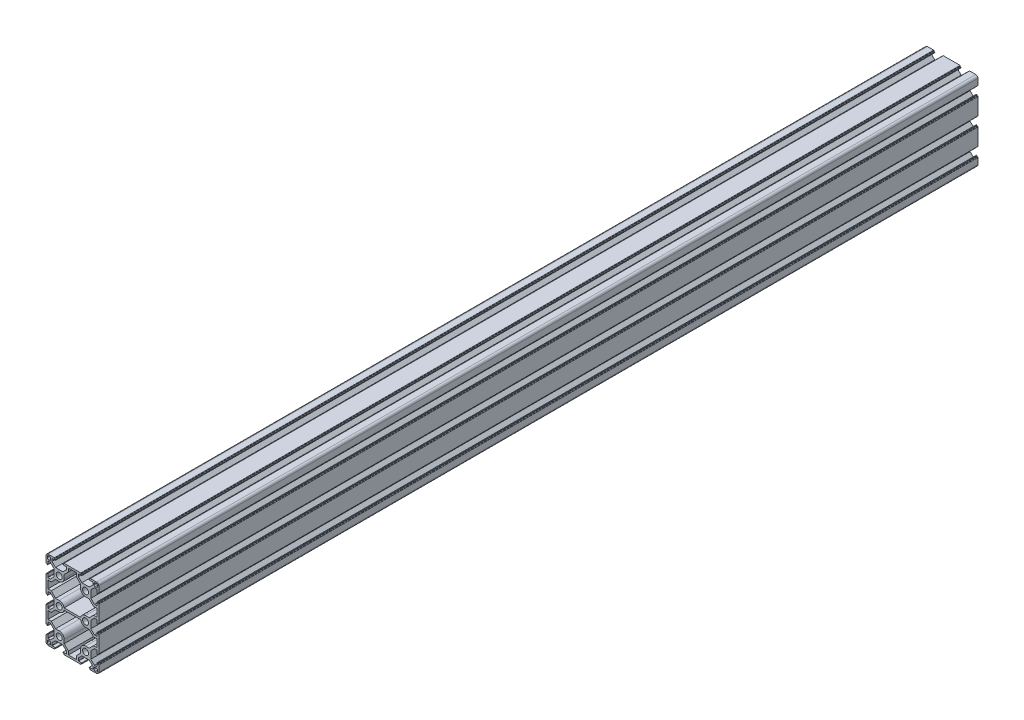
from build123d import *

# Parameters (mm, degrees)
SKETCH_1_R      = 3.4
EXTRUDE_1_DEPTH = 1000


with BuildPart() as part:
    # Эскиз1 → Бобышка-Вытянуть1 (new body)
    with BuildSketch(Plane.XY):
        with BuildLine():
            Line((-30, 38.25), (-30, 42.5))
            ThreePointArc((-30, 42.5), (-29.267766953, 44.267766953), (-27.5, 45))
            Line((-27.5, 45), (-23.25, 45))
            Line((-23.25, 45), (-20.5, 45))
            ThreePointArc((-20.5, 45), (-20.287867966, 44.912132034), (-20.2, 44.7))
            Line((-20.2, 44.7), (-20.2, 44.3))
            ThreePointArc((-20.2, 44.3), (-20.112132034, 44.087867966), (-19.9, 44))
            Line((-19.9, 44), (-19.4, 44))
            ThreePointArc((-19.4, 44), (-19.187867966, 43.912132034), (-19.1, 43.7))
            Line((-19.1, 43.7), (-19.1, 43.3))
            ThreePointArc((-19.1, 43.3), (-19.187867966, 43.087867966), (-19.4, 43))
            Line((-19.4, 43), (-22.95, 43))
            ThreePointArc((-22.95, 43), (-23.162132034, 42.912132034), (-23.25, 42.7))
            Line((-23.25, 42.7), (-23.25, 40.05))
            Line((-23.25, 40.05), (-19.2, 36))
            Line((-19.2, 36), (-10.8, 36))
            Line((-10.8, 36), (-6.75, 40.05))
            Line((-6.75, 40.05), (-6.75, 42.7))
            ThreePointArc((-6.75, 42.7), (-6.837867966, 42.912132034), (-7.05, 43))
            Line((-7.05, 43), (-10.6, 43))
            ThreePointArc((-10.6, 43), (-10.812132034, 43.087867966), (-10.9, 43.3))
            Line((-10.9, 43.3), (-10.9, 43.7))
            ThreePointArc((-10.9, 43.7), (-10.812132034, 43.912132034), (-10.6, 44))
            Line((-10.6, 44), (-10.1, 44))
            ThreePointArc((-10.1, 44), (-9.887867966, 44.087867966), (-9.8, 44.3))
            Line((-9.8, 44.3), (-9.8, 44.7))
            ThreePointArc((-9.8, 44.7), (-9.712132034, 44.912132034), (-9.5, 45))
            Line((-9.5, 45), (-6.75, 45))
            Line((-6.75, 45), (6.75, 45))
            Line((6.75, 45), (9.5, 45))
            ThreePointArc((9.5, 45), (9.712132034, 44.912132034), (9.8, 44.7))
            Line((9.8, 44.7), (9.8, 44.3))
            ThreePointArc((9.8, 44.3), (9.887867966, 44.087867966), (10.1, 44))
            Line((10.1, 44), (10.6, 44))
            ThreePointArc((10.6, 44), (10.812132034, 43.912132034), (10.9, 43.7))
            Line((10.9, 43.7), (10.9, 43.3))
            ThreePointArc((10.9, 43.3), (10.812132034, 43.087867966), (10.6, 43))
            Line((10.6, 43), (7.05, 43))
            ThreePointArc((7.05, 43), (6.837867966, 42.912132034), (6.75, 42.7))
            Line((6.75, 42.7), (6.75, 40.05))
            Line((6.75, 40.05), (10.8, 36))
            Line((10.8, 36), (19.2, 36))
            Line((19.2, 36), (23.25, 40.05))
            Line((23.25, 40.05), (23.25, 42.7))
            ThreePointArc((23.25, 42.7), (23.162132034, 42.912132034), (22.95, 43))
            Line((22.95, 43), (19.4, 43))
            ThreePointArc((19.4, 43), (19.187867966, 43.087867966), (19.1, 43.3))
            Line((19.1, 43.3), (19.1, 43.7))
            ThreePointArc((19.1, 43.7), (19.187867966, 43.912132034), (19.4, 44))
            Line((19.4, 44), (19.9, 44))
            ThreePointArc((19.9, 44), (20.112132034, 44.087867966), (20.2, 44.3))
            Line((20.2, 44.3), (20.2, 44.7))
            ThreePointArc((20.2, 44.7), (20.287867966, 44.912132034), (20.5, 45))
            Line((20.5, 45), (23.25, 45))
            Line((23.25, 45), (27.5, 45))
            ThreePointArc((27.5, 45), (29.267766953, 44.267766953), (30, 42.5))
            Line((30, 42.5), (30, 38.25))
            Line((30, 38.25), (30, 35.5))
            ThreePointArc((30, 35.5), (29.912132034, 35.287867966), (29.7, 35.2))
            Line((29.7, 35.2), (29.3, 35.2))
            ThreePointArc((29.3, 35.2), (29.087867966, 35.112132034), (29, 34.9))
            Line((29, 34.9), (29, 34.4))
            ThreePointArc((29, 34.4), (28.912132034, 34.187867966), (28.7, 34.1))
            Line((28.7, 34.1), (28.3, 34.1))
            ThreePointArc((28.3, 34.1), (28.087867966, 34.187867966), (28, 34.4))
            Line((28, 34.4), (28, 37.95))
            ThreePointArc((28, 37.95), (27.912132034, 38.162132034), (27.7, 38.25))
            Line((27.7, 38.25), (25.05, 38.25))
            Line((25.05, 38.25), (21, 34.2))
            Line((21, 34.2), (21, 25.8))
            Line((21, 25.8), (25.05, 21.75))
            Line((25.05, 21.75), (27.7, 21.75))
            ThreePointArc((27.7, 21.75), (27.912132034, 21.837867966), (28, 22.05))
            Line((28, 22.05), (28, 25.6))
            ThreePointArc((28, 25.6), (28.087867966, 25.812132034), (28.3, 25.9))
            Line((28.3, 25.9), (28.7, 25.9))
            ThreePointArc((28.7, 25.9), (28.912132034, 25.812132034), (29, 25.6))
            Line((29, 25.6), (29, 25.1))
            ThreePointArc((29, 25.1), (29.087867966, 24.887867966), (29.3, 24.8))
            Line((29.3, 24.8), (29.7, 24.8))
            ThreePointArc((29.7, 24.8), (29.912132034, 24.712132034), (30, 24.5))
            Line((30, 24.5), (30, 21.75))
            Line((30, 21.75), (30, 8.25))
            Line((30, 8.25), (30, 5.5))
            ThreePointArc((30, 5.5), (29.912132034, 5.287867966), (29.7, 5.2))
            Line((29.7, 5.2), (29.3, 5.2))
            ThreePointArc((29.3, 5.2), (29.087867966, 5.112132034), (29, 4.9))
            Line((29, 4.9), (29, 4.4))
            ThreePointArc((29, 4.4), (28.912132034, 4.187867966), (28.7, 4.1))
            Line((28.7, 4.1), (28.3, 4.1))
            ThreePointArc((28.3, 4.1), (28.087867966, 4.187867966), (28, 4.4))
            Line((28, 4.4), (28, 7.95))
            ThreePointArc((28, 7.95), (27.912132034, 8.162132034), (27.7, 8.25))
            Line((27.7, 8.25), (25.05, 8.25))
            Line((25.05, 8.25), (21, 4.2))
            Line((21, 4.2), (21, -4.2))
            Line((21, -4.2), (25.05, -8.25))
            Line((25.05, -8.25), (27.7, -8.25))
            ThreePointArc((27.7, -8.25), (27.912132034, -8.162132034), (28, -7.95))
            Line((28, -7.95), (28, -4.4))
            ThreePointArc((28, -4.4), (28.087867966, -4.187867966), (28.3, -4.1))
            Line((28.3, -4.1), (28.7, -4.1))
            ThreePointArc((28.7, -4.1), (28.912132034, -4.187867966), (29, -4.4))
            Line((29, -4.4), (29, -4.9))
            ThreePointArc((29, -4.9), (29.087867966, -5.112132034), (29.3, -5.2))
            Line((29.3, -5.2), (29.7, -5.2))
            ThreePointArc((29.7, -5.2), (29.912132034, -5.287867966), (30, -5.5))
            Line((30, -5.5), (30, -8.25))
            Line((30, -8.25), (30, -21.75))
            Line((30, -21.75), (30, -24.5))
            ThreePointArc((30, -24.5), (29.912132034, -24.712132034), (29.7, -24.8))
            Line((29.7, -24.8), (29.3, -24.8))
            ThreePointArc((29.3, -24.8), (29.087867966, -24.887867966), (29, -25.1))
            Line((29, -25.1), (29, -25.6))
            ThreePointArc((29, -25.6), (28.912132034, -25.812132034), (28.7, -25.9))
            Line((28.7, -25.9), (28.3, -25.9))
            ThreePointArc((28.3, -25.9), (28.087867966, -25.812132034), (28, -25.6))
            Line((28, -25.6), (28, -22.05))
            ThreePointArc((28, -22.05), (27.912132034, -21.837867966), (27.7, -21.75))
            Line((27.7, -21.75), (25.05, -21.75))
            Line((25.05, -21.75), (21, -25.8))
            Line((21, -25.8), (21, -34.2))
            Line((21, -34.2), (25.05, -38.25))
            Line((25.05, -38.25), (27.7, -38.25))
            ThreePointArc((27.7, -38.25), (27.912132034, -38.162132034), (28, -37.95))
            Line((28, -37.95), (28, -34.4))
            ThreePointArc((28, -34.4), (28.087867966, -34.187867966), (28.3, -34.1))
            Line((28.3, -34.1), (28.7, -34.1))
            ThreePointArc((28.7, -34.1), (28.912132034, -34.187867966), (29, -34.4))
            Line((29, -34.4), (29, -34.9))
            ThreePointArc((29, -34.9), (29.087867966, -35.112132034), (29.3, -35.2))
            Line((29.3, -35.2), (29.7, -35.2))
            ThreePointArc((29.7, -35.2), (29.912132034, -35.287867966), (30, -35.5))
            Line((30, -35.5), (30, -38.25))
            Line((30, -38.25), (30, -42.5))
            ThreePointArc((30, -42.5), (29.267766953, -44.267766953), (27.5, -45))
            Line((27.5, -45), (23.25, -45))
            Line((23.25, -45), (20.5, -45))
            ThreePointArc((20.5, -45), (20.287867966, -44.912132034), (20.2, -44.7))
            Line((20.2, -44.7), (20.2, -44.3))
            ThreePointArc((20.2, -44.3), (20.112132034, -44.087867966), (19.9, -44))
            Line((19.9, -44), (19.4, -44))
            ThreePointArc((19.4, -44), (19.187867966, -43.912132034), (19.1, -43.7))
            Line((19.1, -43.7), (19.1, -43.3))
            ThreePointArc((19.1, -43.3), (19.187867966, -43.087867966), (19.4, -43))
            Line((19.4, -43), (22.95, -43))
            ThreePointArc((22.95, -43), (23.162132034, -42.912132034), (23.25, -42.7))
            Line((23.25, -42.7), (23.25, -40.05))
            Line((23.25, -40.05), (19.2, -36))
            Line((19.2, -36), (10.8, -36))
            Line((10.8, -36), (6.75, -40.05))
            Line((6.75, -40.05), (6.75, -42.7))
            ThreePointArc((6.75, -42.7), (6.837867966, -42.912132034), (7.05, -43))
            Line((7.05, -43), (10.6, -43))
            ThreePointArc((10.6, -43), (10.812132034, -43.087867966), (10.9, -43.3))
            Line((10.9, -43.3), (10.9, -43.7))
            ThreePointArc((10.9, -43.7), (10.812132034, -43.912132034), (10.6, -44))
            Line((10.6, -44), (10.1, -44))
            ThreePointArc((10.1, -44), (9.887867966, -44.087867966), (9.8, -44.3))
            Line((9.8, -44.3), (9.8, -44.7))
            ThreePointArc((9.8, -44.7), (9.712132034, -44.912132034), (9.5, -45))
            Line((9.5, -45), (6.75, -45))
            Line((6.75, -45), (-6.75, -45))
            Line((-6.75, -45), (-9.5, -45))
            ThreePointArc((-9.5, -45), (-9.712132034, -44.912132034), (-9.8, -44.7))
            Line((-9.8, -44.7), (-9.8, -44.3))
            ThreePointArc((-9.8, -44.3), (-9.887867966, -44.087867966), (-10.1, -44))
            Line((-10.1, -44), (-10.6, -44))
            ThreePointArc((-10.6, -44), (-10.812132034, -43.912132034), (-10.9, -43.7))
            Line((-10.9, -43.7), (-10.9, -43.3))
            ThreePointArc((-10.9, -43.3), (-10.812132034, -43.087867966), (-10.6, -43))
            Line((-10.6, -43), (-7.05, -43))
            ThreePointArc((-7.05, -43), (-6.837867966, -42.912132034), (-6.75, -42.7))
            Line((-6.75, -42.7), (-6.75, -40.05))
            Line((-6.75, -40.05), (-10.8, -36))
            Line((-10.8, -36), (-19.2, -36))
            Line((-19.2, -36), (-23.25, -40.05))
            Line((-23.25, -40.05), (-23.25, -42.7))
            ThreePointArc((-23.25, -42.7), (-23.162132034, -42.912132034), (-22.95, -43))
            Line((-22.95, -43), (-19.4, -43))
            ThreePointArc((-19.4, -43), (-19.187867966, -43.087867966), (-19.1, -43.3))
            Line((-19.1, -43.3), (-19.1, -43.7))
            ThreePointArc((-19.1, -43.7), (-19.187867966, -43.912132034), (-19.4, -44))
            Line((-19.4, -44), (-19.9, -44))
            ThreePointArc((-19.9, -44), (-20.112132034, -44.087867966), (-20.2, -44.3))
            Line((-20.2, -44.3), (-20.2, -44.7))
            ThreePointArc((-20.2, -44.7), (-20.287867966, -44.912132034), (-20.5, -45))
            Line((-20.5, -45), (-23.25, -45))
            Line((-23.25, -45), (-27.5, -45))
            ThreePointArc((-27.5, -45), (-29.267766953, -44.267766953), (-30, -42.5))
            Line((-30, -42.5), (-30, -38.25))
            Line((-30, -38.25), (-30, -35.5))
            ThreePointArc((-30, -35.5), (-29.912132034, -35.287867966), (-29.7, -35.2))
            Line((-29.7, -35.2), (-29.3, -35.2))
            ThreePointArc((-29.3, -35.2), (-29.087867966, -35.112132034), (-29, -34.9))
            Line((-29, -34.9), (-29, -34.4))
            ThreePointArc((-29, -34.4), (-28.912132034, -34.187867966), (-28.7, -34.1))
            Line((-28.7, -34.1), (-28.3, -34.1))
            ThreePointArc((-28.3, -34.1), (-28.087867966, -34.187867966), (-28, -34.4))
            Line((-28, -34.4), (-28, -37.95))
            ThreePointArc((-28, -37.95), (-27.912132034, -38.162132034), (-27.7, -38.25))
            Line((-27.7, -38.25), (-25.05, -38.25))
            Line((-25.05, -38.25), (-21, -34.2))
            Line((-21, -34.2), (-21, -25.8))
            Line((-21, -25.8), (-25.05, -21.75))
            Line((-25.05, -21.75), (-27.7, -21.75))
            ThreePointArc((-27.7, -21.75), (-27.912132034, -21.837867966), (-28, -22.05))
            Line((-28, -22.05), (-28, -25.6))
            ThreePointArc((-28, -25.6), (-28.087867966, -25.812132034), (-28.3, -25.9))
            Line((-28.3, -25.9), (-28.7, -25.9))
            ThreePointArc((-28.7, -25.9), (-28.912132034, -25.812132034), (-29, -25.6))
            Line((-29, -25.6), (-29, -25.1))
            ThreePointArc((-29, -25.1), (-29.087867966, -24.887867966), (-29.3, -24.8))
            Line((-29.3, -24.8), (-29.7, -24.8))
            ThreePointArc((-29.7, -24.8), (-29.912132034, -24.712132034), (-30, -24.5))
            Line((-30, -24.5), (-30, -21.75))
            Line((-30, -21.75), (-30, -8.25))
            Line((-30, -8.25), (-30, -5.5))
            ThreePointArc((-30, -5.5), (-29.912132034, -5.287867966), (-29.7, -5.2))
            Line((-29.7, -5.2), (-29.3, -5.2))
            ThreePointArc((-29.3, -5.2), (-29.087867966, -5.112132034), (-29, -4.9))
            Line((-29, -4.9), (-29, -4.4))
            ThreePointArc((-29, -4.4), (-28.912132034, -4.187867966), (-28.7, -4.1))
            Line((-28.7, -4.1), (-28.3, -4.1))
            ThreePointArc((-28.3, -4.1), (-28.087867966, -4.187867966), (-28, -4.4))
            Line((-28, -4.4), (-28, -7.95))
            ThreePointArc((-28, -7.95), (-27.912132034, -8.162132034), (-27.7, -8.25))
            Line((-27.7, -8.25), (-25.05, -8.25))
            Line((-25.05, -8.25), (-21, -4.2))
            Line((-21, -4.2), (-21, 4.2))
            Line((-21, 4.2), (-25.05, 8.25))
            Line((-25.05, 8.25), (-27.7, 8.25))
            ThreePointArc((-27.7, 8.25), (-27.912132034, 8.162132034), (-28, 7.95))
            Line((-28, 7.95), (-28, 4.4))
            ThreePointArc((-28, 4.4), (-28.087867966, 4.187867966), (-28.3, 4.1))
            Line((-28.3, 4.1), (-28.7, 4.1))
            ThreePointArc((-28.7, 4.1), (-28.912132034, 4.187867966), (-29, 4.4))
            Line((-29, 4.4), (-29, 4.9))
            ThreePointArc((-29, 4.9), (-29.087867966, 5.112132034), (-29.3, 5.2))
            Line((-29.3, 5.2), (-29.7, 5.2))
            ThreePointArc((-29.7, 5.2), (-29.912132034, 5.287867966), (-30, 5.5))
            Line((-30, 5.5), (-30, 8.25))
            Line((-30, 8.25), (-30, 21.75))
            Line((-30, 21.75), (-30, 24.5))
            ThreePointArc((-30, 24.5), (-29.912132034, 24.712132034), (-29.7, 24.8))
            Line((-29.7, 24.8), (-29.3, 24.8))
            ThreePointArc((-29.3, 24.8), (-29.087867966, 24.887867966), (-29, 25.1))
            Line((-29, 25.1), (-29, 25.6))
            ThreePointArc((-29, 25.6), (-28.912132034, 25.812132034), (-28.7, 25.9))
            Line((-28.7, 25.9), (-28.3, 25.9))
            ThreePointArc((-28.3, 25.9), (-28.087867966, 25.812132034), (-28, 25.6))
            Line((-28, 25.6), (-28, 22.05))
            ThreePointArc((-28, 22.05), (-27.912132034, 21.837867966), (-27.7, 21.75))
            Line((-27.7, 21.75), (-25.05, 21.75))
            Line((-25.05, 21.75), (-21, 25.8))
            Line((-21, 25.8), (-21, 34.2))
            Line((-21, 34.2), (-25.05, 38.25))
            Line((-25.05, 38.25), (-27.7, 38.25))
            ThreePointArc((-27.7, 38.25), (-27.912132034, 38.162132034), (-28, 37.95))
            Line((-28, 37.95), (-28, 34.4))
            ThreePointArc((-28, 34.4), (-28.087867966, 34.187867966), (-28.3, 34.1))
            Line((-28.3, 34.1), (-28.7, 34.1))
            ThreePointArc((-28.7, 34.1), (-28.912132034, 34.187867966), (-29, 34.4))
            Line((-29, 34.4), (-29, 34.9))
            ThreePointArc((-29, 34.9), (-29.087867966, 35.112132034), (-29.3, 35.2))
            Line((-29.3, 35.2), (-29.7, 35.2))
            ThreePointArc((-29.7, 35.2), (-29.912132034, 35.287867966), (-30, 35.5))
            Line((-30, 35.5), (-30, 38.25))
        make_face()
        with Locations((-15, 30)):
            Circle(SKETCH_1_R, mode=Mode.SUBTRACT)
        with Locations((-15, 0)):
            Circle(SKETCH_1_R, mode=Mode.SUBTRACT)
        with Locations((15, 30)):
            Circle(SKETCH_1_R, mode=Mode.SUBTRACT)
        with Locations((15, 0)):
            Circle(SKETCH_1_R, mode=Mode.SUBTRACT)
        with Locations((-15, -30)):
            Circle(SKETCH_1_R, mode=Mode.SUBTRACT)
        with Locations((15, -30)):
            Circle(SKETCH_1_R, mode=Mode.SUBTRACT)
        with BuildLine():
            Line((4.5, 42.8), (-4.5, 42.8))
            Line((-4.5, 42.8), (-4.5, 38.90588745))
            Line((-4.5, 38.90588745), (-9.3, 34.10588745))
            Line((-9.3, 34.10588745), (-9.3, 30))
            ThreePointArc((-9.3, 30), (-10.969491347, 25.969491347), (-15, 24.3))
            Line((-15, 24.3), (-19.10588745, 24.3))
            Line((-19.10588745, 24.3), (-24.05588745, 19.35))
            Line((-24.05588745, 19.35), (-27.8, 19.35))
            Line((-27.8, 19.35), (-27.8, 10.65))
            Line((-27.8, 10.65), (-24.05588745, 10.65))
            Line((-24.05588745, 10.65), (-19.10588745, 5.7))
            Line((-19.10588745, 5.7), (-15, 5.7))
            ThreePointArc((-15, 5.7), (-11.379226602, 4.402272141), (-9.407147418, 1.1))
            Line((-9.407147418, 1.1), (9.407147418, 1.1))
            ThreePointArc((9.407147418, 1.1), (11.379226602, 4.402272141), (15, 5.7))
            Line((15, 5.7), (19.10588745, 5.7))
            Line((19.10588745, 5.7), (24.05588745, 10.65))
            Line((24.05588745, 10.65), (27.8, 10.65))
            Line((27.8, 10.65), (27.8, 19.35))
            Line((27.8, 19.35), (24.05588745, 19.35))
            Line((24.05588745, 19.35), (19.10588745, 24.3))
            Line((19.10588745, 24.3), (15, 24.3))
            ThreePointArc((15, 24.3), (10.969491347, 25.969491347), (9.3, 30))
            Line((9.3, 30), (9.3, 34.10588745))
            Line((9.3, 34.10588745), (4.5, 38.90588745))
            Line((4.5, 38.90588745), (4.5, 42.8))
        make_face(mode=Mode.SUBTRACT)
        with BuildLine():
            Line((-27.35, 43.55), (-25.95, 43.55))
            ThreePointArc((-25.95, 43.55), (-25.101471863, 43.198528137), (-24.75, 42.35))
            Line((-24.75, 42.35), (-24.75, 40.95))
            ThreePointArc((-24.75, 40.95), (-25.101471863, 40.101471863), (-25.95, 39.75))
            Line((-25.95, 39.75), (-27.35, 39.75))
            ThreePointArc((-27.35, 39.75), (-28.198528137, 40.101471863), (-28.55, 40.95))
            Line((-28.55, 40.95), (-28.55, 42.35))
            ThreePointArc((-28.55, 42.35), (-28.198528137, 43.198528137), (-27.35, 43.55))
        make_face(mode=Mode.SUBTRACT)
        with BuildLine():
            Line((27.35, 43.55), (25.95, 43.55))
            ThreePointArc((25.95, 43.55), (25.101471863, 43.198528137), (24.75, 42.35))
            Line((24.75, 42.35), (24.75, 40.95))
            ThreePointArc((24.75, 40.95), (25.101471863, 40.101471863), (25.95, 39.75))
            Line((25.95, 39.75), (27.35, 39.75))
            ThreePointArc((27.35, 39.75), (28.198528137, 40.101471863), (28.55, 40.95))
            Line((28.55, 40.95), (28.55, 42.35))
            ThreePointArc((28.55, 42.35), (28.198528137, 43.198528137), (27.35, 43.55))
        make_face(mode=Mode.SUBTRACT)
        with BuildLine():
            Line((27.35, -43.55), (25.95, -43.55))
            ThreePointArc((25.95, -43.55), (25.101471863, -43.198528137), (24.75, -42.35))
            Line((24.75, -42.35), (24.75, -40.95))
            ThreePointArc((24.75, -40.95), (25.101471863, -40.101471863), (25.95, -39.75))
            Line((25.95, -39.75), (27.35, -39.75))
            ThreePointArc((27.35, -39.75), (28.198528137, -40.101471863), (28.55, -40.95))
            Line((28.55, -40.95), (28.55, -42.35))
            ThreePointArc((28.55, -42.35), (28.198528137, -43.198528137), (27.35, -43.55))
        make_face(mode=Mode.SUBTRACT)
        with BuildLine():
            Line((-4.5, -42.8), (-4.5, -38.90588745))
            Line((-4.5, -38.90588745), (-9.3, -34.10588745))
            Line((-9.3, -34.10588745), (-9.3, -30))
            ThreePointArc((-9.3, -30), (-10.969491347, -25.969491347), (-15, -24.3))
            Line((-15, -24.3), (-19.10588745, -24.3))
            Line((-19.10588745, -24.3), (-24.05588745, -19.35))
            Line((-24.05588745, -19.35), (-27.8, -19.35))
            Line((-27.8, -19.35), (-27.8, -10.65))
            Line((-27.8, -10.65), (-24.05588745, -10.65))
            Line((-24.05588745, -10.65), (-19.10588745, -5.7))
            Line((-19.10588745, -5.7), (-15, -5.7))
            ThreePointArc((-15, -5.7), (-11.379226602, -4.402272141), (-9.407147418, -1.1))
            Line((-9.407147418, -1.1), (9.407147418, -1.1))
            ThreePointArc((9.407147418, -1.1), (11.379226602, -4.402272141), (15, -5.7))
            Line((15, -5.7), (19.10588745, -5.7))
            Line((19.10588745, -5.7), (24.05588745, -10.65))
            Line((24.05588745, -10.65), (27.8, -10.65))
            Line((27.8, -10.65), (27.8, -19.35))
            Line((27.8, -19.35), (24.05588745, -19.35))
            Line((24.05588745, -19.35), (19.10588745, -24.3))
            Line((19.10588745, -24.3), (15, -24.3))
            ThreePointArc((15, -24.3), (10.969491347, -25.969491347), (9.3, -30))
            Line((9.3, -30), (9.3, -34.10588745))
            Line((9.3, -34.10588745), (4.5, -38.90588745))
            Line((4.5, -38.90588745), (4.5, -42.8))
            Line((4.5, -42.8), (-4.5, -42.8))
        make_face(mode=Mode.SUBTRACT)
        with BuildLine():
            Line((-27.35, -43.55), (-25.95, -43.55))
            ThreePointArc((-25.95, -43.55), (-25.101471863, -43.198528137), (-24.75, -42.35))
            Line((-24.75, -42.35), (-24.75, -40.95))
            ThreePointArc((-24.75, -40.95), (-25.101471863, -40.101471863), (-25.95, -39.75))
            Line((-25.95, -39.75), (-27.35, -39.75))
            ThreePointArc((-27.35, -39.75), (-28.198528137, -40.101471863), (-28.55, -40.95))
            Line((-28.55, -40.95), (-28.55, -42.35))
            ThreePointArc((-28.55, -42.35), (-28.198528137, -43.198528137), (-27.35, -43.55))
        make_face(mode=Mode.SUBTRACT)
    extrude(amount=EXTRUDE_1_DEPTH)


solid = part.part
